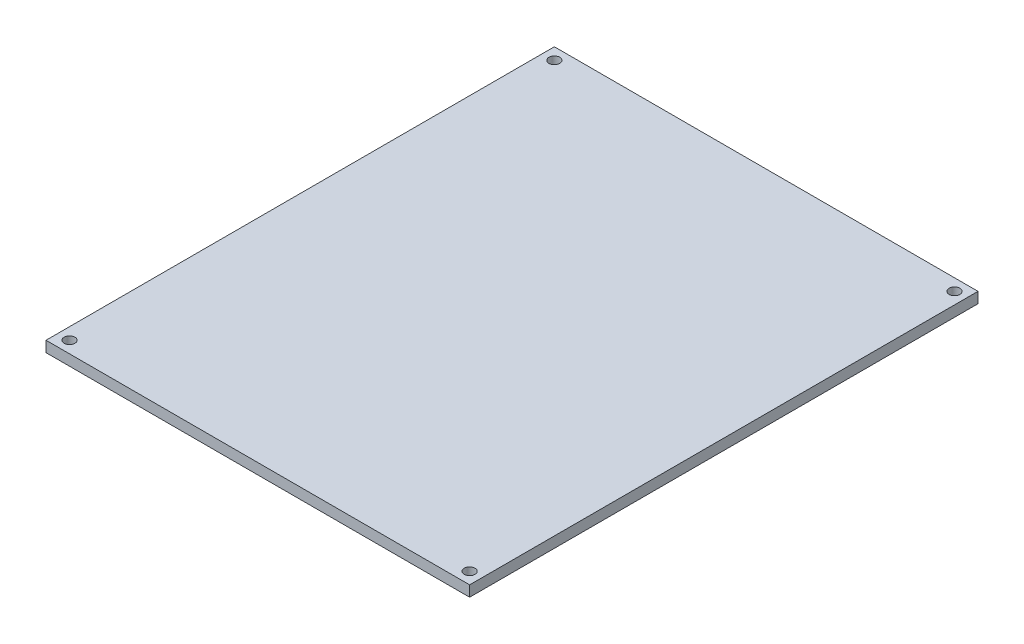
from build123d import *

# Parameters (mm, degrees)
SKETCH1_W           = 100
SKETCH1_H           = 120
BOSS_EXTRUDE1_DEPTH = 2.54
SKETCH2_R           = 1.27
CUT_EXTRUDE1_DEPTH  = 3.54


with BuildPart() as part:
    # Sketch1 → Boss-Extrude1 (new body)
    with BuildSketch(Plane(origin=(0, 0, 0), x_dir=(1, 0, 0), z_dir=(0, 1, 0))):
        with Locations((50, 60)):
            Rectangle(SKETCH1_W, SKETCH1_H)
    extrude(amount=BOSS_EXTRUDE1_DEPTH)

    # Sketch2 → Cut-Extrude1 (cut, through all)
    with BuildSketch(Plane(origin=(0, 2.54, 0), x_dir=(1, 0, 0), z_dir=(0, 1, 0))):
        with Locations((2.774461538, 117.225538462)):
            Circle(SKETCH2_R)
        with Locations((97.225538462, 117.225538462)):
            Circle(SKETCH2_R)
        with Locations((97.225538462, 2.774461538)):
            Circle(SKETCH2_R)
        with Locations((2.774461538, 2.774461538)):
            Circle(SKETCH2_R)
    extrude(amount=-CUT_EXTRUDE1_DEPTH, mode=Mode.SUBTRACT)


solid = part.part
